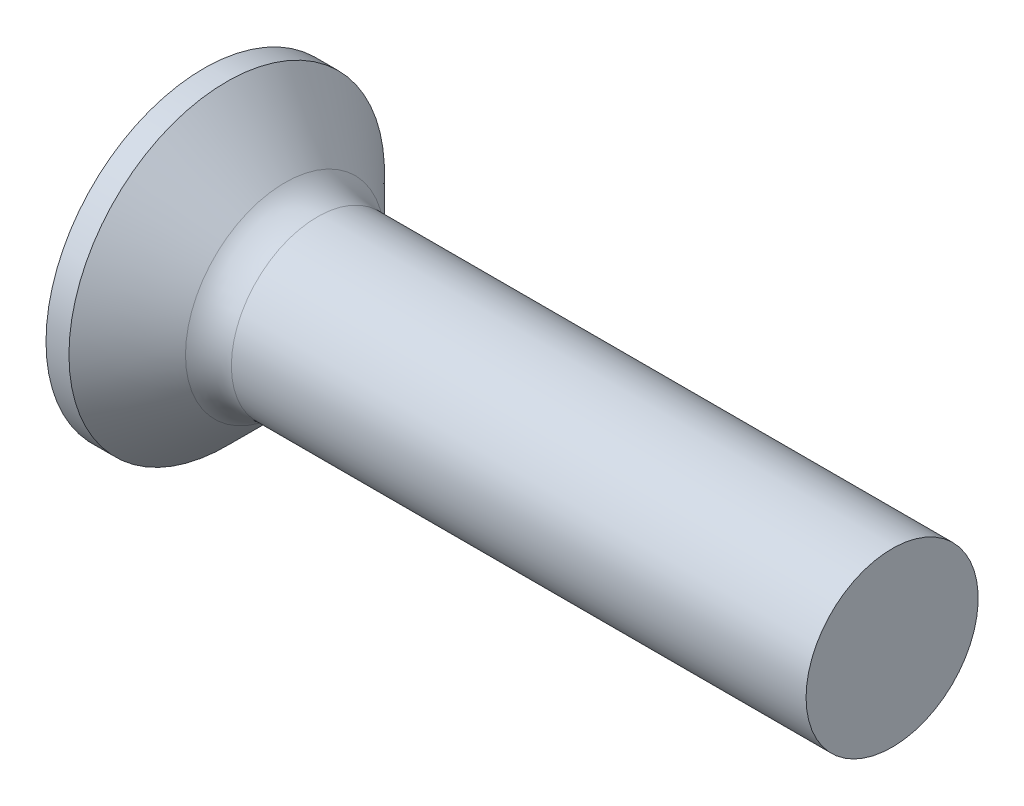
from build123d import *

# Parameters (mm, degrees)
FILLET1_R    = 0.8
SKETCH3_W    = 0.74
SKETCH3_H    = 3
SKETCH4_W    = 0.74
SKETCH4_H    = 0.99570227
RECPAT_COUNT = 2
RECPAT_ANGLE = 90


with BuildPart() as part:
    # BodySke → Base-Revolve (revolve)
    with BuildSketch(Plane.XY):
        Polygon((0, 0), (0, 2.75), (0.4, 2.75), (1.65, 1.5), (12, 1.5), (12, 0), align=None)
    revolve(axis=Axis((-6.35, 0, 0), (1, 0, 0)))

    # Fillet1
    fillet1_edges = [part.edges().sort_by_distance(p)[0] for p in [
        (1.65, -1.5, 0),
    ]]
    fillet(fillet1_edges, radius=FILLET1_R)

    # Sketch3 → Recess section 0
    with BuildSketch(Plane.ZY):
        Rectangle(SKETCH3_W, SKETCH3_H)
    # Sketch4 → Recess section 1
    with BuildSketch(Plane.ZY.offset(-2.01)):
        Rectangle(SKETCH4_W, SKETCH4_H)
    recess = loft(mode=Mode.SUBTRACT)

    # RecPat: Recess ×2 about axis
    recpat_axis = Axis((0, 0, 0), (1, 0, 0))
    for i in range(1, RECPAT_COUNT):
        add(recess.rotate(recpat_axis, i * RECPAT_ANGLE / (RECPAT_COUNT - 1)), mode=Mode.SUBTRACT)

    # RecCorSke → RecessCore (revolve, cut)
    with BuildSketch(Plane.XY):
        Polygon((0, 0), (0, 0.696552892), (2.01, 0.556), (2.190655351, 0), align=None)
    revolve(axis=Axis((-3.175, 0, 0), (1, 0, 0)), mode=Mode.SUBTRACT)


solid = part.part
